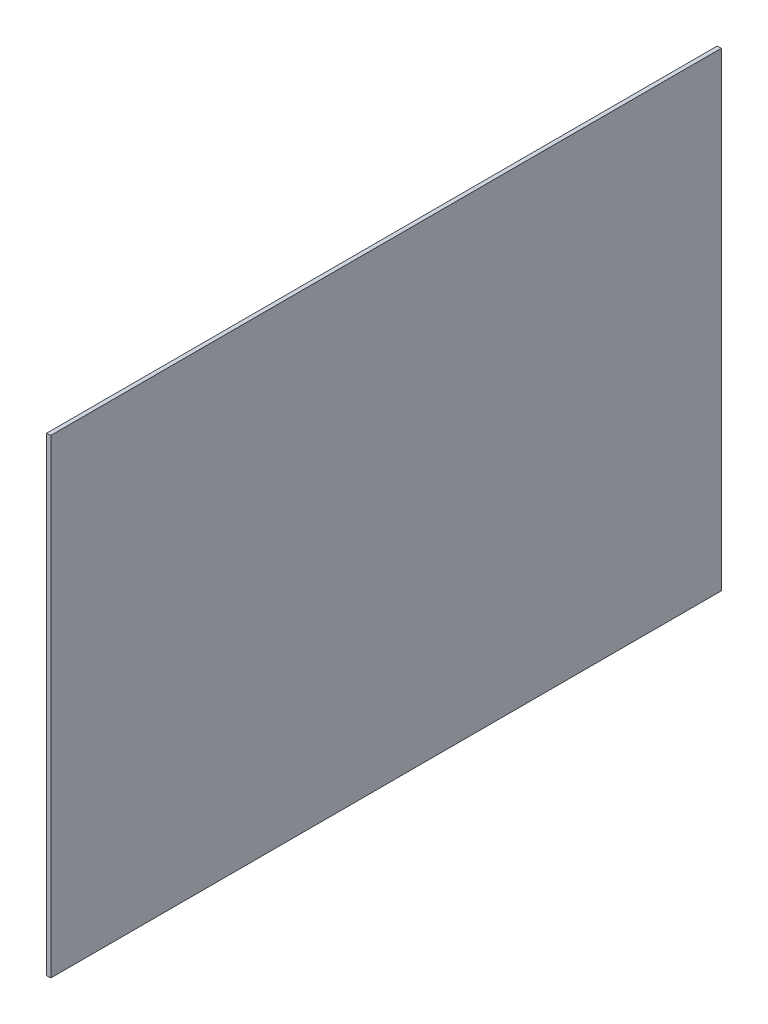
from build123d import *

# Parameters (mm, degrees)
SKETCH1_W           = 500
SKETCH1_H           = 350.410610824
BOSS_EXTRUDE1_DEPTH = 3


with BuildPart() as part:
    # Sketch1 → Boss-Extrude1 (new body)
    with BuildSketch(Plane(origin=(0, 0, 0), x_dir=(0, 0, -1), z_dir=(1, 0, 0))):
        Rectangle(SKETCH1_W, SKETCH1_H)
    extrude(amount=BOSS_EXTRUDE1_DEPTH)


solid = part.part
